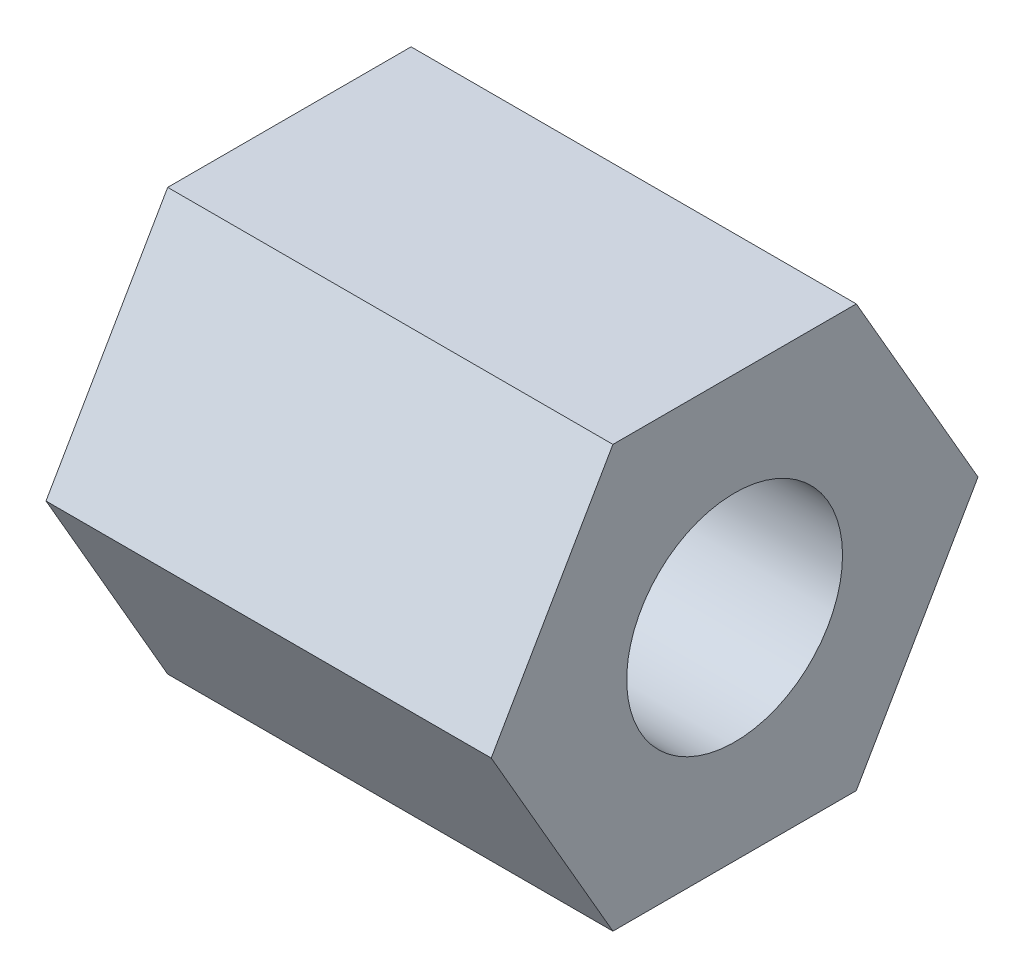
from build123d import *

# Parameters (mm, degrees)
BOSS_EXTRUDE1_DEPTH   = 5.03
F_2_CLEARANCE_HOLE1_D = 2.4384


with BuildPart() as part:
    # Sketch1 → Boss-Extrude1 (new body)
    with BuildSketch(Plane(origin=(0, 0, 0), x_dir=(0, 0, -1), z_dir=(1, 0, 0))):
        Polygon((2.749630657, 0), (1.374815329, 2.38125), (-1.374815329, 2.38125), (-2.749630657, 0), (-1.374815329, -2.38125), (1.374815329, -2.38125), align=None)
    extrude(amount=BOSS_EXTRUDE1_DEPTH)

    # #2 Clearance Hole1 (through all)
    with Locations(Plane(origin=(5.03, 0, 0), x_dir=(0, 0, -1), z_dir=(1, 0, 0))):
        with Locations((0, 0)):
            Hole(F_2_CLEARANCE_HOLE1_D / 2)


solid = part.part
